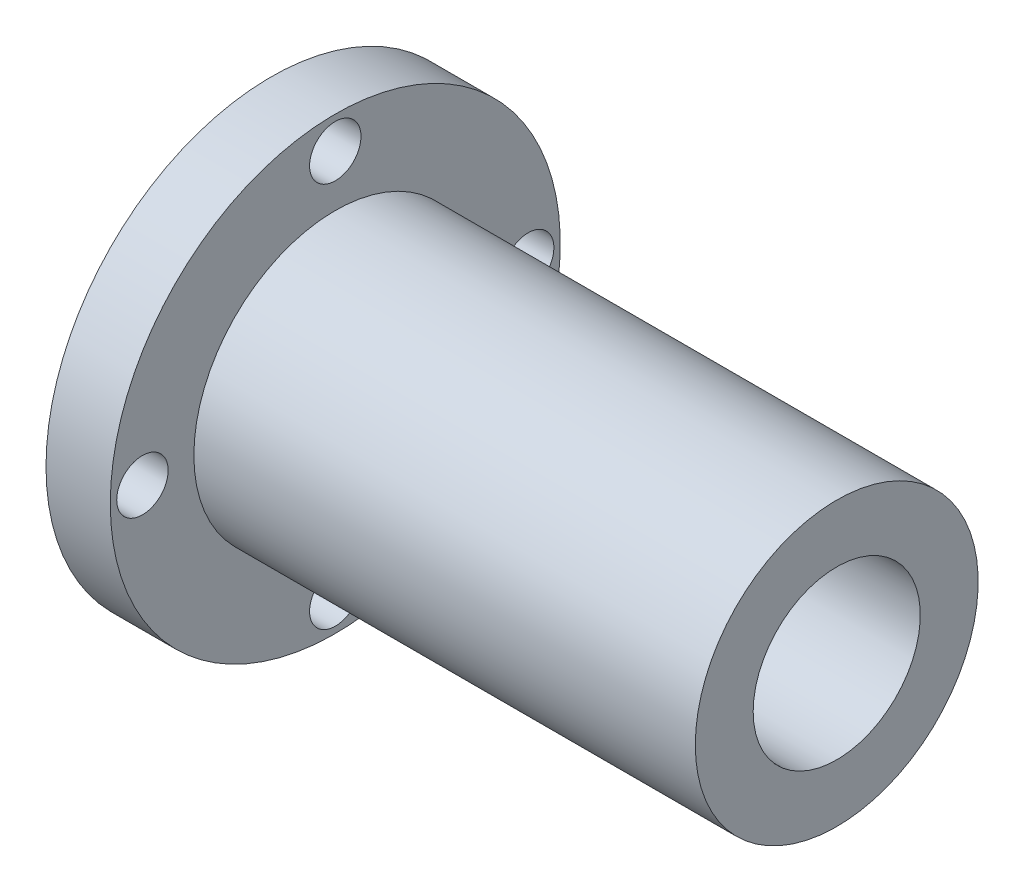
from build123d import *

# Parameters (mm, degrees)
ESQUISSE2_R      = 2
EXTRUSION1_DEPTH = 45


with BuildPart() as part:
    # Esquisse1 → Révolution1 (revolve)
    with BuildSketch(Plane.XY):
        Polygon((0, 10), (0, 17.5), (5, 17.5), (5, 11), (44, 11), (44, 6.5), (20, 6.5), (20, 10), align=None)
    revolve(axis=Axis((0, 0, 0), (1, 0, 0)))

    # Esquisse2 → Extrusion1 (cut, through all)
    with BuildSketch(Plane.ZY):
        with Locations((0, 15)):
            Circle(ESQUISSE2_R)
        with Locations((15, 0)):
            Circle(ESQUISSE2_R)
        with Locations((0, -15)):
            Circle(ESQUISSE2_R)
        with Locations((-15, 0)):
            Circle(ESQUISSE2_R)
    extrude(amount=-EXTRUSION1_DEPTH, mode=Mode.SUBTRACT)


solid = part.part
